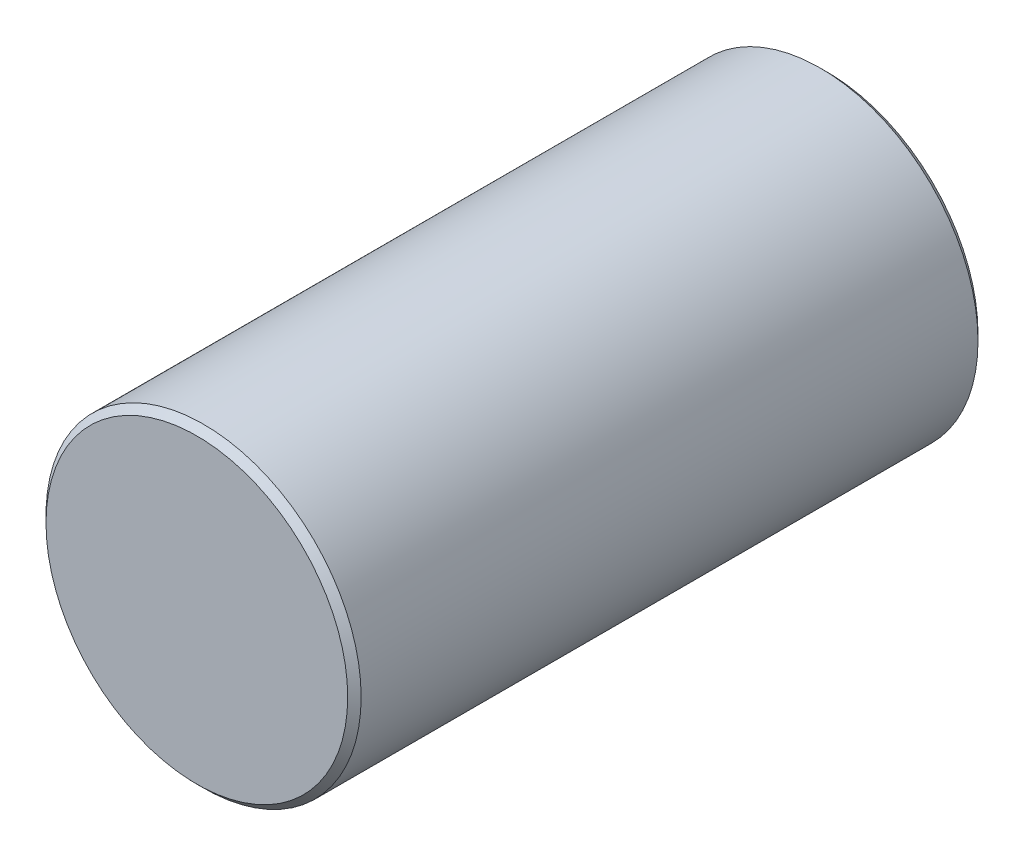
from build123d import *

# Parameters (mm, degrees)
SKETCH1_R         = 9.525
EXTRUDE1_DEPTH    = 19.05
CHAMFER1_SIZE     = 0.4064
SKETCH6_R         = 1.984375
BLIND_HOLES_DEPTH = 12.7


with BuildPart() as part:
    # Sketch1 → Extrude1 (new body, symmetric)
    with BuildSketch(Plane.XY):
        Circle(SKETCH1_R)
    extrude(amount=EXTRUDE1_DEPTH, both=True)

    # Chamfer1
    chamfer1_edges = [part.edges().sort_by_distance(p)[0] for p in [
        (-9.525, 0, -19.05),
        (-9.525, 0, 19.05),
    ]]
    chamfer(chamfer1_edges, length=CHAMFER1_SIZE)

    # Sketch6 → Blind Holes (cut)
    with BuildSketch(Plane(origin=(0, -9.525, 0), x_dir=(-1, 0, 0), z_dir=(0, 1, 0))):
        with Locations(Location((0, 12.7, 0), (0, 0, 270))):  # turned: the seam where the file's is
            Circle(SKETCH6_R)
        with Locations(Location((0, -12.7, 0), (0, 0, 270))):  # turned: the seam where the file's is
            Circle(SKETCH6_R)
    extrude(amount=BLIND_HOLES_DEPTH, mode=Mode.SUBTRACT)


solid = part.part
